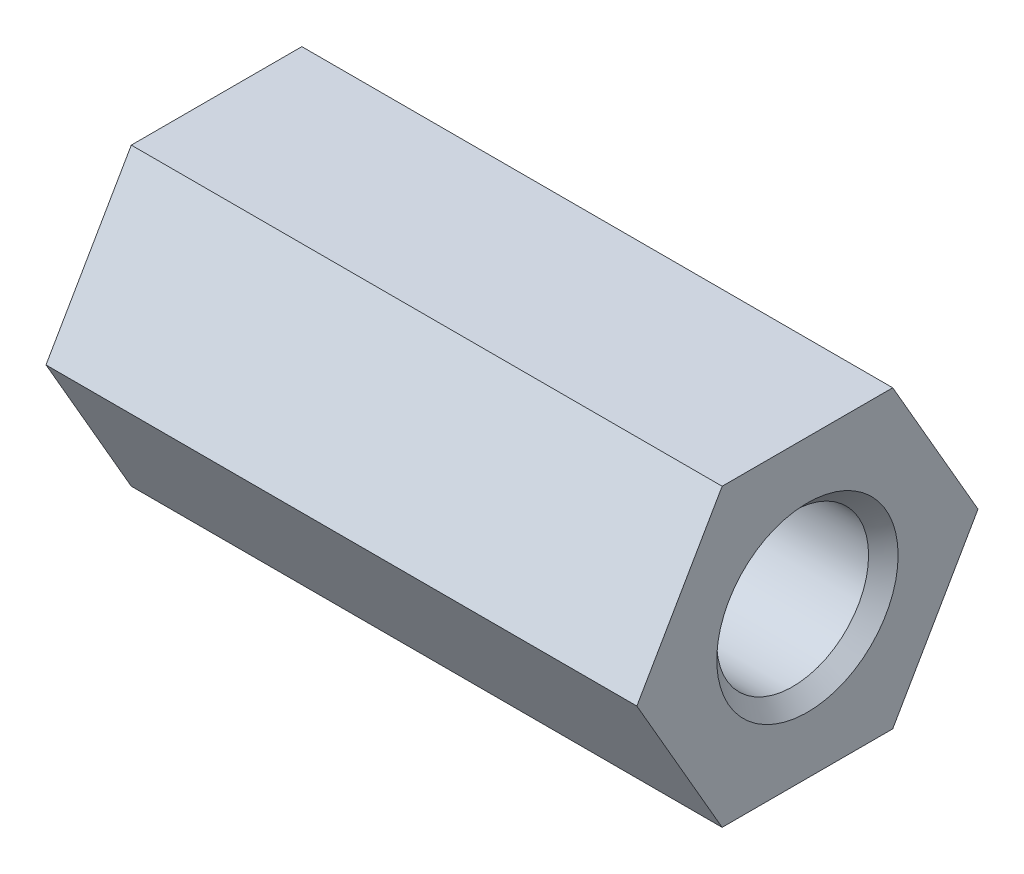
from build123d import *

# Parameters (mm, degrees)
BOSS_EXTRUDE1_DEPTH                    = 25.4
TAP_DRILL_FOR_5_16_18_TAP1_D           = 6.5278
TAP_DRILL_FOR_5_16_18_TAP1_CSINK_D     = 7.7978
TAP_DRILL_FOR_5_16_18_TAP1_CSINK_ANGLE = 90


with BuildPart() as part:
    # Sketch1 → Boss-Extrude1 (new body)
    with BuildSketch(Plane(origin=(0, 0, 0), x_dir=(0, 0, -1), z_dir=(1, 0, 0))):
        Polygon((7.332348419, 0), (3.666174209, 6.35), (-3.666174209, 6.35), (-7.332348419, 0), (-3.666174209, -6.35), (3.666174209, -6.35), align=None)
    extrude(amount=BOSS_EXTRUDE1_DEPTH)

    # Tap Drill for 5/16-18 Tap1 (through all)
    with Locations(Plane(origin=(25.4, 0, 0), x_dir=(0, 0, -1), z_dir=(1, 0, 0))):
        with Locations((0, 0)):
            CounterSinkHole(TAP_DRILL_FOR_5_16_18_TAP1_D / 2, TAP_DRILL_FOR_5_16_18_TAP1_CSINK_D / 2, counter_sink_angle=TAP_DRILL_FOR_5_16_18_TAP1_CSINK_ANGLE)


solid = part.part
